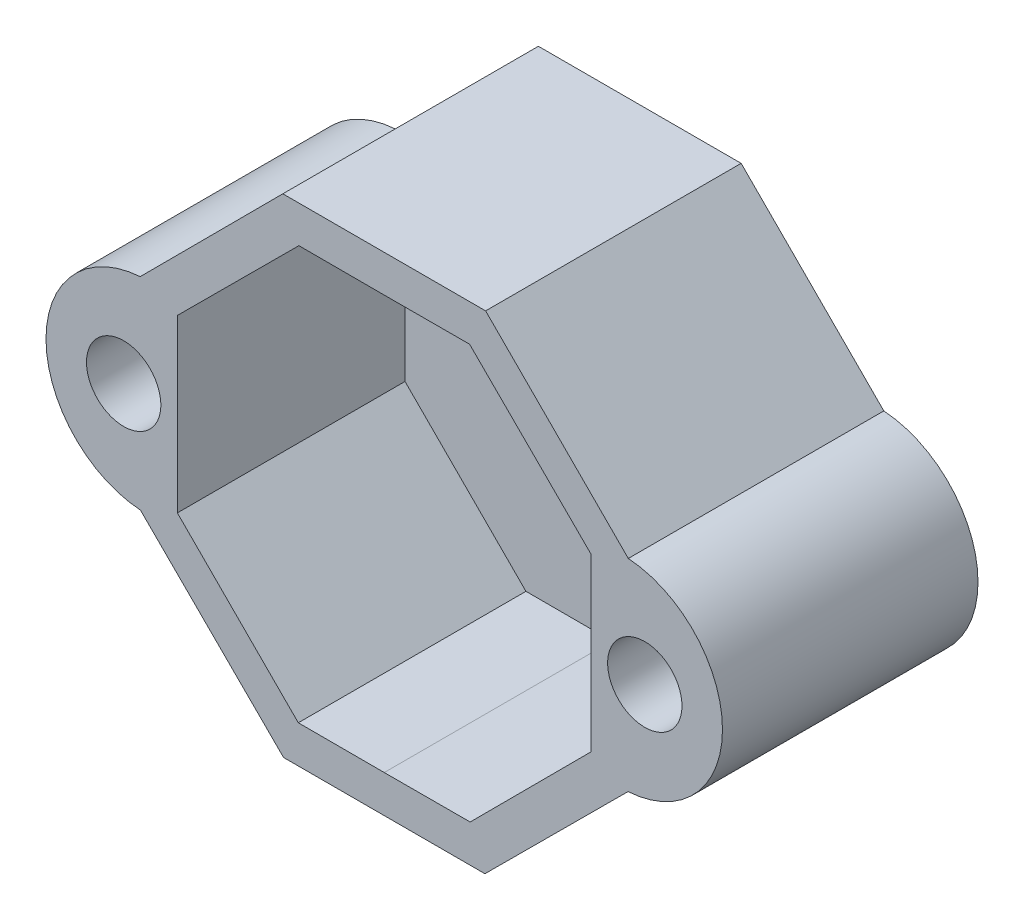
from build123d import *

# Parameters (mm, degrees)
SKETCH1_R           = 1.600000124
BOSS_EXTRUDE1_DEPTH = 9.8
SKETCH2_R           = 3.949999995
BOSS_EXTRUDE2_DEPTH = 1.2


with BuildPart() as part:
    # Sketch1 → Boss-Extrude1 (new body)
    with BuildSketch(Plane.XY.offset(11)):
        with BuildLine():
            Line((4.333958961, -10.506317019), (10.493660346, -4.364516586))
            ThreePointArc((10.493660346, -4.364516586), (14.560364187, -0.021186842), (10.506317019, 4.333958961))
            Line((10.506317019, 4.333958961), (4.364516586, 10.493660346))
            Line((4.364516586, 10.493660346), (-4.364516586, 10.493660346))
            Line((-4.364516586, 10.493660346), (-10.506317019, 4.333958961))
            ThreePointArc((-10.506317019, 4.333958961), (-14.560364187, -0.021186842), (-10.493660346, -4.364516586))
            Line((-10.493660346, -4.364516586), (-4.333958961, -10.506317019))
            Line((-4.333958961, -10.506317019), (4.333958961, -10.506317019))
        make_face()
        with Locations((11.217179708, -0.008876194)):
            Circle(SKETCH1_R, mode=Mode.SUBTRACT)
        with Locations((-11.217179708, -0.008876194)):
            Circle(SKETCH1_R, mode=Mode.SUBTRACT)
        Polygon((0, 8.900009778), (3.673546249, 8.905354887), (8.894626983, 3.699447494), (8.905354887, -3.673546249), (3.699447494, -8.894626983), (0, -8.900009778), (-3.699447494, -8.894626983), (-8.905354887, -3.673546249), (-8.894626983, 3.699447494), (-3.673546249, 8.905354887), align=None, mode=Mode.SUBTRACT)
    extrude(amount=-BOSS_EXTRUDE1_DEPTH)

    # Sketch2 → Boss-Extrude2 (add)
    with BuildSketch(Plane(origin=(0, 0, 1.2), x_dir=(-1, 0, 0), z_dir=(0, 0, -1))):
        with BuildLine():
            Line((4.364516586, 10.493660346), (-4.364516586, 10.493660346))
            Line((-4.364516586, 10.493660346), (-10.506317019, 4.333958961))
            ThreePointArc((-10.506317019, 4.333958961), (-14.560364187, -0.021186842), (-10.493660346, -4.364516586))
            Line((-10.493660346, -4.364516586), (-4.333958961, -10.506317019))
            Line((-4.333958961, -10.506317019), (4.333958961, -10.506317019))
            Line((4.333958961, -10.506317019), (10.493660346, -4.364516586))
            ThreePointArc((10.493660346, -4.364516586), (14.560364187, -0.021186842), (10.506317019, 4.333958961))
            Line((10.506317019, 4.333958961), (4.364516586, 10.493660346))
        make_face()
        Circle(SKETCH2_R, mode=Mode.SUBTRACT)
    extrude(amount=BOSS_EXTRUDE2_DEPTH)


solid = part.part
